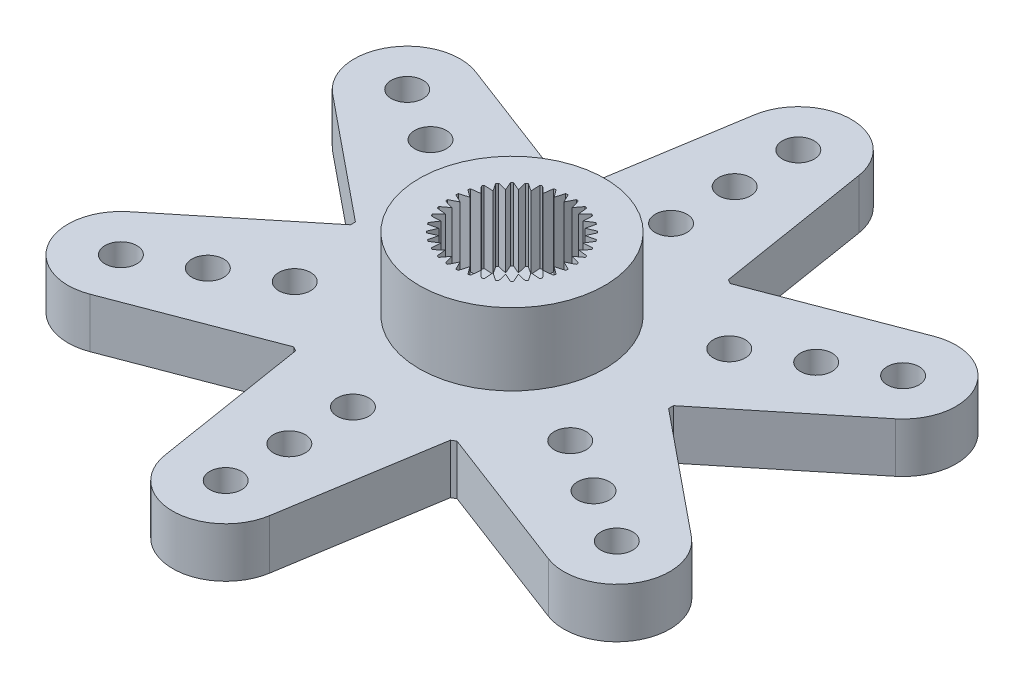
from build123d import *

# Parameters (mm, degrees)
BOSS_EXTRUDE1_DEPTH                                 = 2.35
SKETCH2_R                                           = 4.375
BOSS_EXTRUDE2_DEPTH                                 = 3.4
CUT_EXTRUDE1_DEPTH                                  = 3.4
HOLE1_D                                             = 8.8
HOLE1_DEPTH                                         = 0.3
SKETCH6_W                                           = 3.25
SKETCH6_H                                           = 0.3
F_00_CLEARANCE_HOLE1_D                              = 1.5
F_00_CLEARANCE_HOLE1_DEPTH                          = 2.35
CBORE_FOR_3_BINDING_HEAD_MACHINE_SCREW1_D           = 3
CBORE_FOR_3_BINDING_HEAD_MACHINE_SCREW1_DEPTH       = 5.75
CBORE_FOR_3_BINDING_HEAD_MACHINE_SCREW1_CBORE_D     = 5.5
CBORE_FOR_3_BINDING_HEAD_MACHINE_SCREW1_CBORE_DEPTH = 0.3


with BuildPart() as part:
    # Sketch1 → Boss-Extrude1 (new body)
    with BuildSketch(Plane(origin=(0, 2.35, 0), x_dir=(1, 0, 0), z_dir=(0, 1, 0))):
        with BuildLine():
            Line((-3.65, -6.551908119), (-2.46825946, -13.897108598))
            ThreePointArc((-2.46825946, -13.897108598), (0, -16), (2.46825946, -13.897108598))
            Line((2.46825946, -13.897108598), (3.65, -6.551908119))
            ThreePointArc((3.65, -6.551908119), (3.75, -6.495190528), (3.849118874, -6.436946783))
            Line((3.849118874, -6.436946783), (10.801119355, -9.086129695))
            ThreePointArc((10.801119355, -9.086129695), (13.856406461, -8), (13.269378815, -4.810978904))
            Line((13.269378815, -4.810978904), (7.499118874, -0.114961336))
            ThreePointArc((7.499118874, -0.114961336), (7.5, 0), (7.499118874, 0.114961336))
            Line((7.499118874, 0.114961336), (13.269378815, 4.810978904))
            ThreePointArc((13.269378815, 4.810978904), (13.856406461, 8), (10.801119355, 9.086129695))
            Line((10.801119355, 9.086129695), (3.849118874, 6.436946783))
            ThreePointArc((3.849118874, 6.436946783), (3.75, 6.495190528), (3.65, 6.551908119))
            Line((3.65, 6.551908119), (2.46825946, 13.897108598))
            ThreePointArc((2.46825946, 13.897108598), (0, 16), (-2.46825946, 13.897108598))
            Line((-2.46825946, 13.897108598), (-3.65, 6.551908119))
            ThreePointArc((-3.65, 6.551908119), (-3.75, 6.495190528), (-3.849118874, 6.436946783))
            Line((-3.849118874, 6.436946783), (-10.801119355, 9.086129695))
            ThreePointArc((-10.801119355, 9.086129695), (-13.856406461, 8), (-13.269378815, 4.810978904))
            Line((-13.269378815, 4.810978904), (-7.499118874, 0.114961336))
            ThreePointArc((-7.499118874, 0.114961336), (-7.5, 0), (-7.499118874, -0.114961336))
            Line((-7.499118874, -0.114961336), (-13.269378815, -4.810978904))
            ThreePointArc((-13.269378815, -4.810978904), (-13.856406461, -8), (-10.801119355, -9.086129695))
            Line((-10.801119355, -9.086129695), (-3.849118874, -6.436946783))
            ThreePointArc((-3.849118874, -6.436946783), (-3.75, -6.495190528), (-3.65, -6.551908119))
        make_face()
    extrude(amount=-BOSS_EXTRUDE1_DEPTH)

    # Sketch2 → Boss-Extrude2 (add)
    with BuildSketch(Plane(origin=(0, 2.35, 0), x_dir=(-1, 0, 0), z_dir=(0, 1, 0))):
        Circle(SKETCH2_R)
    extrude(amount=BOSS_EXTRUDE2_DEPTH)

    # Sketch3 → Cut-Extrude1 (cut)
    with BuildSketch(Plane(origin=(0, 5.75, 0), x_dir=(-1, 0, 0), z_dir=(0, 1, 0))):
        with BuildLine():
            Line((0.687336745, 2.765875666), (0.425438035, 2.412778995))
            Line((0.425438035, 2.412778995), (0.300099924, 2.834155965))
            ThreePointArc((0.300099924, 2.834155965), (0.248393867, 2.83915489), (0.196605286, 2.843210573))
            Line((0.196605286, 2.843210573), (0, 2.45))
            Line((0, 2.45), (-0.196605286, 2.843210573))
            ThreePointArc((-0.196605286, 2.843210573), (-0.248393867, 2.83915489), (-0.300099924, 2.834155965))
            Line((-0.300099924, 2.834155965), (-0.425438035, 2.412778995))
            Line((-0.425438035, 2.412778995), (-0.687336745, 2.765875666))
            ThreePointArc((-0.687336745, 2.765875666), (-0.737634279, 2.752888605), (-0.787686751, 2.738986963))
            Line((-0.787686751, 2.738986963), (-0.837949351, 2.302246921))
            Line((-0.837949351, 2.302246921), (-1.157183824, 2.604501026))
            ThreePointArc((-1.157183824, 2.604501026), (-1.204462046, 2.582977193), (-1.251340114, 2.560595228))
            Line((-1.251340114, 2.560595228), (-1.225, 2.121762239))
            Line((-1.225, 2.121762239), (-1.591870459, 2.363989941))
            ThreePointArc((-1.591870459, 2.363989941), (-1.634692844, 2.334583326), (-1.676972141, 2.304401102))
            Line((-1.676972141, 2.304401102), (-1.574829644, 1.876808886))
            Line((-1.574829644, 1.876808886), (-1.978188915, 2.051650218))
            ThreePointArc((-1.978188915, 2.051650218), (-2.015254326, 2.015254326), (-2.051650218, 1.978188915))
            Line((-2.051650218, 1.978188915), (-1.876808886, 1.574829644))
            Line((-1.876808886, 1.574829644), (-2.304401102, 1.676972141))
            ThreePointArc((-2.304401102, 1.676972141), (-2.334583326, 1.634692844), (-2.363989941, 1.591870459))
            Line((-2.363989941, 1.591870459), (-2.121762239, 1.225))
            Line((-2.121762239, 1.225), (-2.560595228, 1.251340114))
            ThreePointArc((-2.560595228, 1.251340114), (-2.582977193, 1.204462046), (-2.604501026, 1.157183824))
            Line((-2.604501026, 1.157183824), (-2.302246921, 0.837949351))
            Line((-2.302246921, 0.837949351), (-2.738986963, 0.787686751))
            ThreePointArc((-2.738986963, 0.787686751), (-2.752888605, 0.737634279), (-2.765875666, 0.687336745))
            Line((-2.765875666, 0.687336745), (-2.412778995, 0.425438035))
            Line((-2.412778995, 0.425438035), (-2.834155965, 0.300099924))
            ThreePointArc((-2.834155965, 0.300099924), (-2.83915489, 0.248393867), (-2.843210573, 0.196605286))
            Line((-2.843210573, 0.196605286), (-2.45, 0))
            Line((-2.45, 0), (-2.843210573, -0.196605286))
            ThreePointArc((-2.843210573, -0.196605286), (-2.83915489, -0.248393867), (-2.834155965, -0.300099924))
            Line((-2.834155965, -0.300099924), (-2.412778995, -0.425438035))
            Line((-2.412778995, -0.425438035), (-2.765875666, -0.687336745))
            ThreePointArc((-2.765875666, -0.687336745), (-2.752888605, -0.737634279), (-2.738986963, -0.787686751))
            Line((-2.738986963, -0.787686751), (-2.302246921, -0.837949351))
            Line((-2.302246921, -0.837949351), (-2.604501026, -1.157183824))
            ThreePointArc((-2.604501026, -1.157183824), (-2.582977193, -1.204462046), (-2.560595228, -1.251340114))
            Line((-2.560595228, -1.251340114), (-2.121762239, -1.225))
            Line((-2.121762239, -1.225), (-2.363989941, -1.591870459))
            ThreePointArc((-2.363989941, -1.591870459), (-2.334583326, -1.634692844), (-2.304401102, -1.676972141))
            Line((-2.304401102, -1.676972141), (-1.876808886, -1.574829644))
            Line((-1.876808886, -1.574829644), (-2.051650218, -1.978188915))
            ThreePointArc((-2.051650218, -1.978188915), (-2.015254326, -2.015254326), (-1.978188915, -2.051650218))
            Line((-1.978188915, -2.051650218), (-1.574829644, -1.876808886))
            Line((-1.574829644, -1.876808886), (-1.676972141, -2.304401102))
            ThreePointArc((-1.676972141, -2.304401102), (-1.634692844, -2.334583326), (-1.591870459, -2.363989941))
            Line((-1.591870459, -2.363989941), (-1.225, -2.121762239))
            Line((-1.225, -2.121762239), (-1.251340114, -2.560595228))
            ThreePointArc((-1.251340114, -2.560595228), (-1.204462046, -2.582977193), (-1.157183824, -2.604501026))
            Line((-1.157183824, -2.604501026), (-0.837949351, -2.302246921))
            Line((-0.837949351, -2.302246921), (-0.787686751, -2.738986963))
            ThreePointArc((-0.787686751, -2.738986963), (-0.737634279, -2.752888605), (-0.687336745, -2.765875666))
            Line((-0.687336745, -2.765875666), (-0.425438035, -2.412778995))
            Line((-0.425438035, -2.412778995), (-0.300099924, -2.834155965))
            ThreePointArc((-0.300099924, -2.834155965), (-0.248393867, -2.83915489), (-0.196605286, -2.843210573))
            Line((-0.196605286, -2.843210573), (0, -2.45))
            Line((0, -2.45), (0.196605286, -2.843210573))
            ThreePointArc((0.196605286, -2.843210573), (0.248393867, -2.83915489), (0.300099924, -2.834155965))
            Line((0.300099924, -2.834155965), (0.425438035, -2.412778995))
            Line((0.425438035, -2.412778995), (0.687336745, -2.765875666))
            ThreePointArc((0.687336745, -2.765875666), (0.737634279, -2.752888605), (0.787686751, -2.738986963))
            Line((0.787686751, -2.738986963), (0.837949351, -2.302246921))
            Line((0.837949351, -2.302246921), (1.157183824, -2.604501026))
            ThreePointArc((1.157183824, -2.604501026), (1.204462046, -2.582977193), (1.251340114, -2.560595228))
            Line((1.251340114, -2.560595228), (1.225, -2.121762239))
            Line((1.225, -2.121762239), (1.591870459, -2.363989941))
            ThreePointArc((1.591870459, -2.363989941), (1.634692844, -2.334583326), (1.676972141, -2.304401102))
            Line((1.676972141, -2.304401102), (1.574829644, -1.876808886))
            Line((1.574829644, -1.876808886), (1.978188915, -2.051650218))
            ThreePointArc((1.978188915, -2.051650218), (2.015254326, -2.015254326), (2.051650218, -1.978188915))
            Line((2.051650218, -1.978188915), (1.876808886, -1.574829644))
            Line((1.876808886, -1.574829644), (2.304401102, -1.676972141))
            ThreePointArc((2.304401102, -1.676972141), (2.334583326, -1.634692844), (2.363989941, -1.591870459))
            Line((2.363989941, -1.591870459), (2.121762239, -1.225))
            Line((2.121762239, -1.225), (2.560595228, -1.251340114))
            ThreePointArc((2.560595228, -1.251340114), (2.582977193, -1.204462046), (2.604501026, -1.157183824))
            Line((2.604501026, -1.157183824), (2.302246921, -0.837949351))
            Line((2.302246921, -0.837949351), (2.738986963, -0.787686751))
            ThreePointArc((2.738986963, -0.787686751), (2.752888605, -0.737634279), (2.765875666, -0.687336745))
            Line((2.765875666, -0.687336745), (2.412778995, -0.425438035))
            Line((2.412778995, -0.425438035), (2.834155965, -0.300099924))
            ThreePointArc((2.834155965, -0.300099924), (2.83915489, -0.248393867), (2.843210573, -0.196605286))
            Line((2.843210573, -0.196605286), (2.45, 0))
            Line((2.45, 0), (2.843210573, 0.196605286))
            ThreePointArc((2.843210573, 0.196605286), (2.83915489, 0.248393867), (2.834155965, 0.300099924))
            Line((2.834155965, 0.300099924), (2.412778995, 0.425438035))
            Line((2.412778995, 0.425438035), (2.765875666, 0.687336745))
            ThreePointArc((2.765875666, 0.687336745), (2.752888605, 0.737634279), (2.738986963, 0.787686751))
            Line((2.738986963, 0.787686751), (2.302246921, 0.837949351))
            Line((2.302246921, 0.837949351), (2.604501026, 1.157183824))
            ThreePointArc((2.604501026, 1.157183824), (2.582977193, 1.204462046), (2.560595228, 1.251340114))
            Line((2.560595228, 1.251340114), (2.121762239, 1.225))
            Line((2.121762239, 1.225), (2.363989941, 1.591870459))
            ThreePointArc((2.363989941, 1.591870459), (2.334583326, 1.634692844), (2.304401102, 1.676972141))
            Line((2.304401102, 1.676972141), (1.876808886, 1.574829644))
            Line((1.876808886, 1.574829644), (2.051650218, 1.978188915))
            ThreePointArc((2.051650218, 1.978188915), (2.015254326, 2.015254326), (1.978188915, 2.051650218))
            Line((1.978188915, 2.051650218), (1.574829644, 1.876808886))
            Line((1.574829644, 1.876808886), (1.676972141, 2.304401102))
            ThreePointArc((1.676972141, 2.304401102), (1.634692844, 2.334583326), (1.591870459, 2.363989941))
            Line((1.591870459, 2.363989941), (1.225, 2.121762239))
            Line((1.225, 2.121762239), (1.251340114, 2.560595228))
            ThreePointArc((1.251340114, 2.560595228), (1.204462046, 2.582977193), (1.157183824, 2.604501026))
            Line((1.157183824, 2.604501026), (0.837949351, 2.302246921))
            Line((0.837949351, 2.302246921), (0.787686751, 2.738986963))
            ThreePointArc((0.787686751, 2.738986963), (0.737634279, 2.752888605), (0.687336745, 2.765875666))
        make_face()
    extrude(amount=-CUT_EXTRUDE1_DEPTH, mode=Mode.SUBTRACT)

    # Hole1
    with Locations(Plane(origin=(0, 0, 0), x_dir=(-1, 0, 0), z_dir=(0, -1, 0))):
        with Locations((0, 0)):
            Hole(HOLE1_D / 2, depth=HOLE1_DEPTH)

    # Sketch6 → Revolve1 (revolve)
    with BuildSketch(Plane.XY):
        with Locations((1.625, 0.15)):
            Rectangle(SKETCH6_W, SKETCH6_H)
    revolve(axis=Axis((0, 0.3, 0), (0, -1, 0)))

    # #00 Clearance Hole1
    with Locations(Plane(origin=(0, 2.35, 0), x_dir=(1, 0, 0), z_dir=(0, 1, 0))):
        with Locations((0, -13.5), (0, -7.5), (0, -10.5), (11.691342951, -6.75), (6.495190528, -3.75), (9.09326674, -5.25), (11.691342951, 6.75), (6.495190528, 3.75), (9.09326674, 5.25), (0, 13.5), (0, 7.5), (0, 10.5), (-11.691342951, 6.75), (-6.495190528, 3.75), (-9.09326674, 5.25), (-11.691342951, -6.75), (-6.495190528, -3.75), (-9.09326674, -5.25)):
            Hole(F_00_CLEARANCE_HOLE1_D / 2, depth=F_00_CLEARANCE_HOLE1_DEPTH)

    # CBORE for #3 Binding Head Machine Screw1
    with Locations(Plane(origin=(0, 0, 0), x_dir=(-1, 0, 0), z_dir=(0, -1, 0))):
        with Locations((0, 0)):
            CounterBoreHole(CBORE_FOR_3_BINDING_HEAD_MACHINE_SCREW1_D / 2, CBORE_FOR_3_BINDING_HEAD_MACHINE_SCREW1_CBORE_D / 2, CBORE_FOR_3_BINDING_HEAD_MACHINE_SCREW1_CBORE_DEPTH, depth=CBORE_FOR_3_BINDING_HEAD_MACHINE_SCREW1_DEPTH)


solid = part.part
